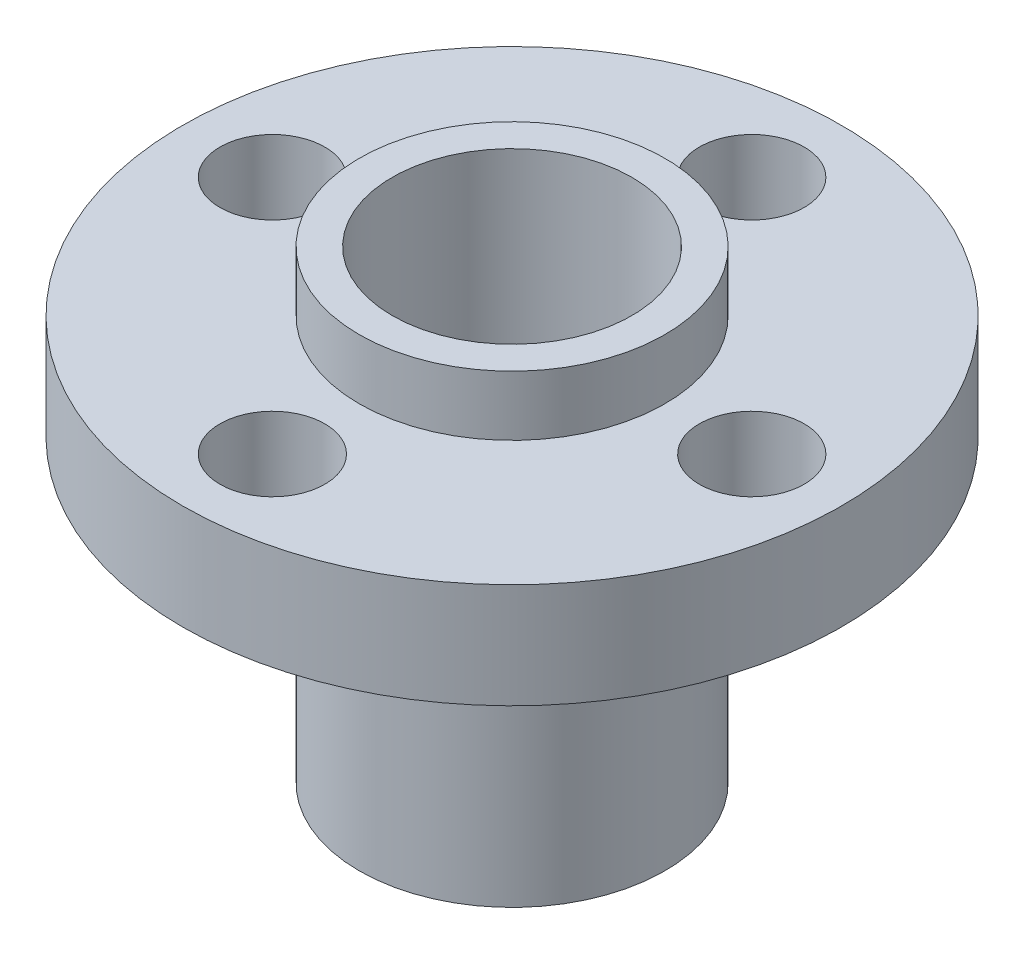
from build123d import *

# Parameters (mm, degrees)
SKETCH_1_R          = 5.1
EXTRUDE_1_DEPTH     = 10
SKETCH_2_R          = 11
EXTRUDE_2_DEPTH     = 3.5
SKETCH_3_R          = 5.1
EXTRUDE_3_DEPTH     = 2
SKETCH_4_R          = 4
SKETCH_4_R_2        = 1.75
CUT_EXTRUDE_1_DEPTH = 16.5


with BuildPart() as part:
    # 草图1 → 凸台-拉伸1 (new body)
    with BuildSketch(Plane(origin=(0, 0, 0), x_dir=(1, 0, 0), z_dir=(0, 1, 0))):
        Circle(SKETCH_1_R)
    extrude(amount=EXTRUDE_1_DEPTH)

    # 草图2 → 凸台-拉伸2 (add)
    with BuildSketch(Plane(origin=(0, 10, 0), x_dir=(1, 0, 0), z_dir=(0, 1, 0))):
        Circle(SKETCH_2_R)
    extrude(amount=EXTRUDE_2_DEPTH)

    # 草图3 → 凸台-拉伸3 (add)
    with BuildSketch(Plane(origin=(0, 13.5, 0), x_dir=(1, 0, 0), z_dir=(0, 1, 0))):
        Circle(SKETCH_3_R)
    extrude(amount=EXTRUDE_3_DEPTH)

    # 草图4 → 切除-拉伸1 (cut, through all)
    with BuildSketch(Plane(origin=(0, 15.5, 0), x_dir=(1, 0, 0), z_dir=(0, 1, 0))):
        Circle(SKETCH_4_R)
        with Locations((-8, 0)):
            Circle(SKETCH_4_R_2)
        with Locations((0, -8)):
            Circle(SKETCH_4_R_2)
        with Locations((8, 0)):
            Circle(SKETCH_4_R_2)
        with Locations((0, 8)):
            Circle(SKETCH_4_R_2)
    extrude(amount=-CUT_EXTRUDE_1_DEPTH, mode=Mode.SUBTRACT)


solid = part.part
